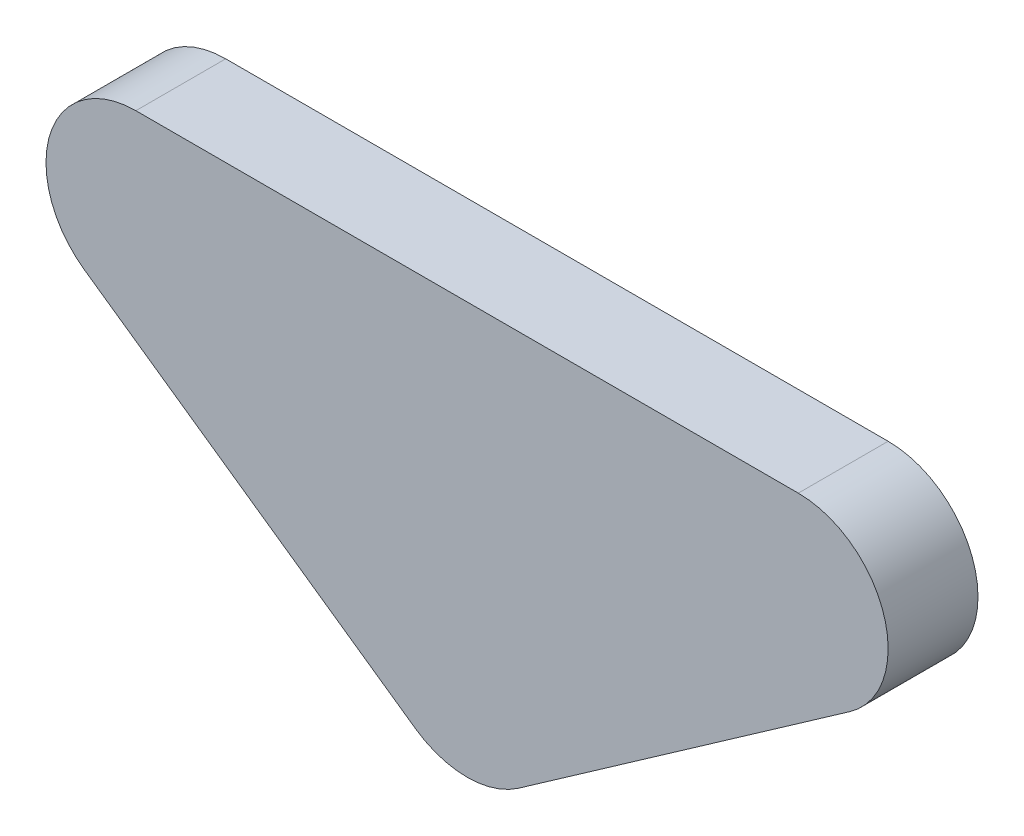
from build123d import *

# Parameters (mm, degrees)
EXTRUDE_1_DEPTH = 10


with BuildPart() as part:
    # 草图1 → 凸台-拉伸1 (new body)
    with BuildSketch(Plane.XY):
        with BuildLine():
            Line((5.735764364, -8.191520443), (42.597606357, 17.619419193))
            ThreePointArc((42.597606357, 17.619419193), (46.3990115, 28.817997631), (36.861841993, 35.810939636))
            Line((36.861841993, 35.810939636), (-36.861841993, 35.810939636))
            ThreePointArc((-36.861841993, 35.810939636), (-46.3990115, 28.817997631), (-42.597606357, 17.619419193))
            Line((-42.597606357, 17.619419193), (-5.735764364, -8.191520443))
            ThreePointArc((-5.735764364, -8.191520443), (0, -10), (5.735764364, -8.191520443))
        make_face()
    extrude(amount=EXTRUDE_1_DEPTH)


solid = part.part
